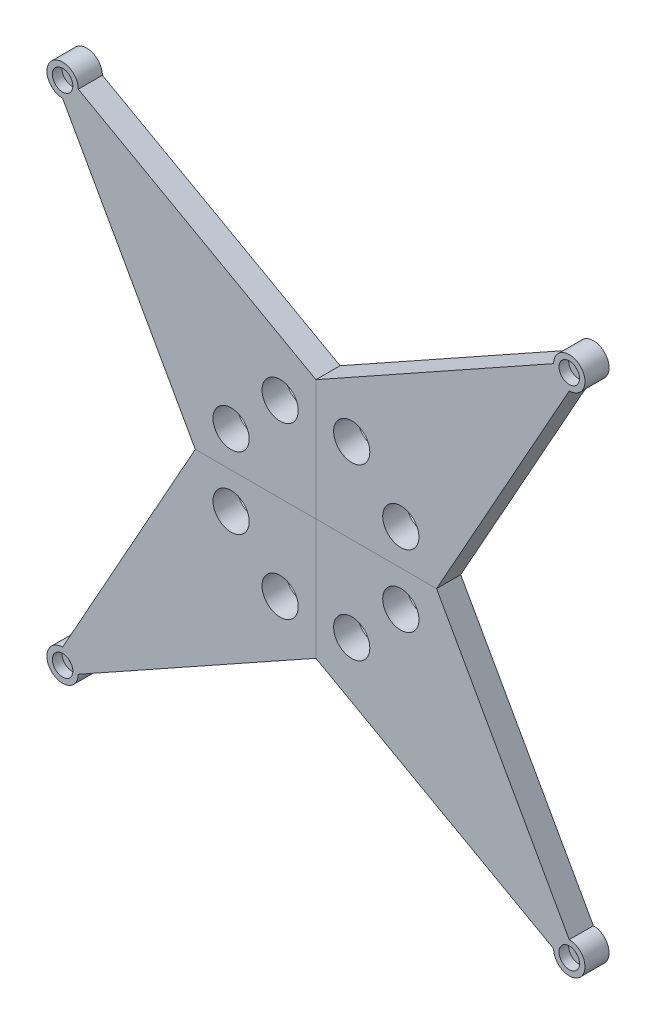
from build123d import *

# Parameters (mm, degrees)
RESSALTO_EXTRUS_O2_DEPTH = 5
ESBO_O4_R                = 4.25
CORTE_EXTRUS_O1_DEPTH    = 4
ESBO_O5_R                = 1.5
CORTE_EXTRUS_O2_DEPTH    = 7
ESBO_O6_R                = 7.5
CORTE_EXTRUS_O3_DEPTH    = 11


with BuildPart() as part:
    # Esboço3 → Ressalto-extrusão2 (new body, symmetric)
    with BuildSketch(Plane.XY):
        with BuildLine():
            Line((0, 50), (98.5, 105))
            ThreePointArc((98.5, 105), (109.596194078, 109.596194078), (105, 98.5))
            Line((105, 98.5), (50, 0))
            Line((50, 0), (0, 0))
            Line((0, 0), (0, 50))
        make_face()
    extrude(amount=RESSALTO_EXTRUS_O2_DEPTH, both=True)

    # Esboço4 → Corte-extrusão1 (cut)
    with BuildSketch(Plane.XY.offset(5)):
        with Locations((105, 105)):
            Circle(ESBO_O4_R)
    extrude(amount=-CORTE_EXTRUS_O1_DEPTH, mode=Mode.SUBTRACT)

    # Esboço5 → Corte-extrusão2 (cut, through all)
    with BuildSketch(Plane.XY.offset(1)):
        with Locations((105, 105)):
            Circle(ESBO_O5_R)
    extrude(amount=-CORTE_EXTRUS_O2_DEPTH, mode=Mode.SUBTRACT)

    # Esboço6 → Corte-extrusão3 (cut, through all)
    with BuildSketch(Plane.XY.offset(5)):
        with Locations((14.825558834, 35.174441166)):
            Circle(ESBO_O6_R)
        with Locations((35.174441166, 14.825558834)):
            Circle(ESBO_O6_R)
    extrude(amount=-CORTE_EXTRUS_O3_DEPTH, mode=Mode.SUBTRACT)


with BuildPart() as body_2:
    # Espelhar1: mirrored copy
    add(part.part.mirror(Plane(origin=(0, 0, 5), x_dir=(0, 0, 1), z_dir=(0, 1, 0))))


with BuildPart() as body_3:
    # Espelhar2: mirrored copy
    add(body_2.part.mirror(Plane(origin=(0, 0, 5), x_dir=(0, 0, 1), z_dir=(1, 0, 0))))


with BuildPart() as body_4:
    # Espelhar2 2: mirrored copy
    add(part.part.mirror(Plane(origin=(0, 0, 5), x_dir=(0, 0, 1), z_dir=(1, 0, 0))))


solid = Compound([part.part, body_2.part, body_3.part, body_4.part])
